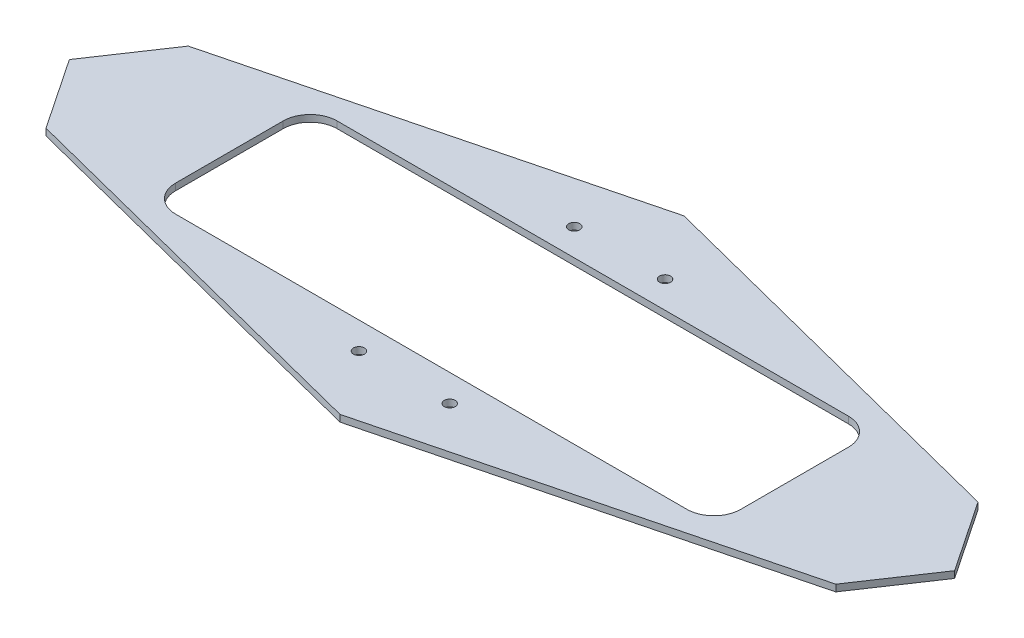
from build123d import *

# Parameters (mm, degrees)
BOSS_EXTRUDE1_DEPTH     = 3.175
SKETCH2_R               = 5.159375
CUT_EXTRUDE1_DEPTH      = 4.175
CUT_EXTRUDE1_DEPTH_BACK = 4.175


with BuildPart() as part:
    # Sketch1 → Boss-Extrude1 (new body, symmetric)
    with BuildSketch(Plane(origin=(0, 0, 0), x_dir=(1, 0, 0), z_dir=(0, 1, 0))):
        Polygon((-372.691935385, 67.129264749), (0, 162.283527596), (372.691935385, 67.129264749), (417.779308923, 0), (372.691935385, -67.129264749), (0, -162.283527596), (-372.691935385, -67.129264749), (-417.779308923, 0), align=None)
    extrude(amount=BOSS_EXTRUDE1_DEPTH, both=True)

    # Sketch2 → Cut-Extrude1 (cut, two sides)
    with BuildSketch(Plane(origin=(0, 0, 0), x_dir=(1, 0, 0), z_dir=(0, 1, 0))) as cut_extrude1_sk:
        with Locations((42.8625, 101.6)):
            Circle(SKETCH2_R)
        with Locations((-42.8625, 101.6)):
            Circle(SKETCH2_R)
        with Locations((-42.8625, -101.6)):
            Circle(SKETCH2_R)
        with Locations((42.8625, -101.6)):
            Circle(SKETCH2_R)
        with BuildLine():
            Line((241.3, 76.2), (-241.3, 76.2))
            ThreePointArc((-241.3, 76.2), (-259.260512242, 68.760512242), (-266.7, 50.8))
            Line((-266.7, 50.8), (-266.7, -50.8))
            ThreePointArc((-266.7, -50.8), (-259.260512242, -68.760512242), (-241.3, -76.2))
            Line((-241.3, -76.2), (241.3, -76.2))
            ThreePointArc((241.3, -76.2), (259.260512242, -68.760512242), (266.7, -50.8))
            Line((266.7, -50.8), (266.7, 50.8))
            ThreePointArc((266.7, 50.8), (259.260512242, 68.760512242), (241.3, 76.2))
        make_face()
    extrude(amount=CUT_EXTRUDE1_DEPTH, mode=Mode.SUBTRACT)
    extrude(cut_extrude1_sk.sketch, amount=-CUT_EXTRUDE1_DEPTH_BACK, mode=Mode.SUBTRACT)


solid = part.part
